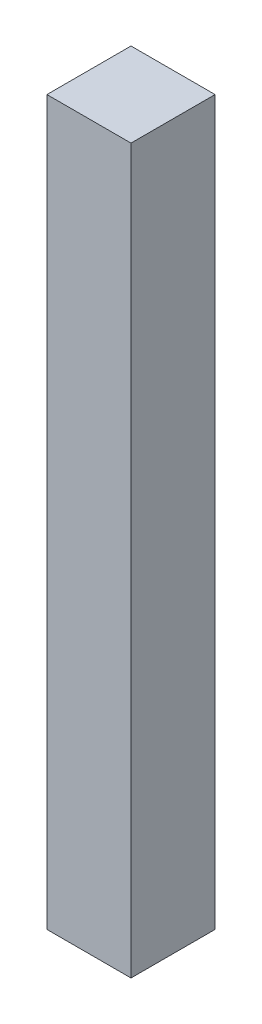
from build123d import *

# Parameters (mm, degrees)
SKETCH1_W           = 10
SKETCH1_H           = 10
BOSS_EXTRUDE1_DEPTH = 86


with BuildPart() as part:
    # Sketch1 → Boss-Extrude1 (new body)
    with BuildSketch(Plane(origin=(0, 0, 0), x_dir=(1, 0, 0), z_dir=(0, 1, 0))):
        with Locations((5, -5)):
            Rectangle(SKETCH1_W, SKETCH1_H)
    extrude(amount=BOSS_EXTRUDE1_DEPTH)


solid = part.part
